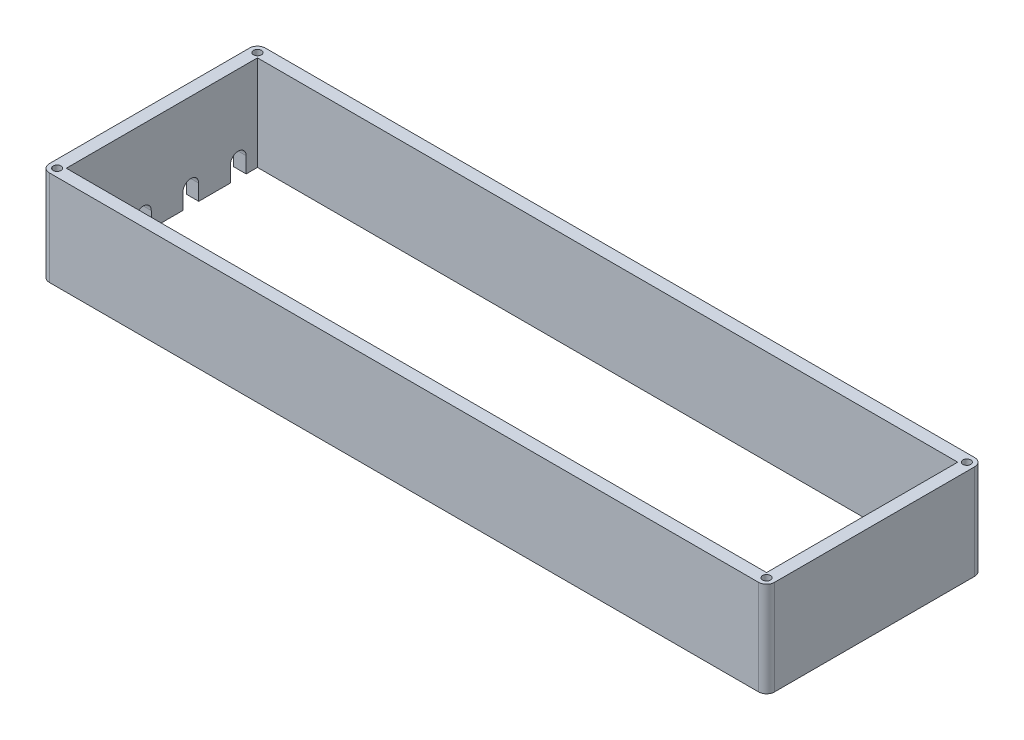
from build123d import *

# Parameters (mm, degrees)
SKETCH1_R           = 3.175
SKETCH1_W           = 562.160000372
SKETCH1_H           = 153.482
BOSS_EXTRUDE1_DEPTH = 76.2
CUT_EXTRUDE1_REACH  = 662.854


with BuildPart() as part:
    # Sketch1 → Boss-Extrude1 (new body)
    with BuildSketch(Plane(origin=(0, 0, 0), x_dir=(1, 0, 0), z_dir=(0, 1, 0))):
        with BuildLine():
            Line((-514.30312852, -129.851740003), (-1083.763128892, -129.851740003))
            ThreePointArc((-1083.763128892, -129.851740003), (-1088.253256953, -131.711611942), (-1090.113128892, -136.201740003))
            Line((-1090.113128892, -136.201740003), (-1090.113128892, -296.983740003))
            ThreePointArc((-1090.113128892, -296.983740003), (-1088.253256953, -301.473868063), (-1083.763128892, -303.333740003))
            Line((-1083.763128892, -303.333740003), (-514.30312852, -303.333740003))
            ThreePointArc((-514.30312852, -303.333740003), (-509.81300046, -301.473868063), (-507.95312852, -296.983740003))
            Line((-507.95312852, -296.983740003), (-507.95312852, -136.201740003))
            ThreePointArc((-507.95312852, -136.201740003), (-509.81300046, -131.711611942), (-514.30312852, -129.851740003))
        make_face()
        with Locations(Location((-1083.763128892, -136.201740003, 0), (0, 0, 90))):
            Circle(SKETCH1_R, mode=Mode.SUBTRACT)
        with Locations(Location((-1083.763128892, -296.983740003, 0), (0, 0, 90))):
            Circle(SKETCH1_R, mode=Mode.SUBTRACT)
        with Locations(Location((-514.30312852, -136.201740003, 0), (0, 0, 90))):
            Circle(SKETCH1_R, mode=Mode.SUBTRACT)
        with Locations(Location((-514.30312852, -296.983740003, 0), (0, 0, 90))):
            Circle(SKETCH1_R, mode=Mode.SUBTRACT)
        with Locations((-799.033128706, -216.592740003)):
            Rectangle(SKETCH1_W, SKETCH1_H, mode=Mode.SUBTRACT)
    extrude(amount=BOSS_EXTRUDE1_DEPTH)

    # Sketch3 → Cut-Extrude1 (cut, up to next)
    with BuildSketch(Plane.ZY.offset(1090.113128892), mode=Mode.PRIVATE) as cut_extrude1_sk1:
        with BuildLine():
            Line((161.601740003, 0), (148.901740003, 0))
            Line((148.901740003, 0), (148.901740003, 12.7))
            ThreePointArc((148.901740003, 12.7), (155.251740003, 19.05), (161.601740003, 12.7))
            Line((161.601740003, 12.7), (161.601740003, 0))
        make_face()
    cut_extrude1_tool1 = extrude(cut_extrude1_sk1.sketch, amount=-CUT_EXTRUDE1_REACH, mode=Mode.PRIVATE) & part.part
    # Sketch3 → Cut-Extrude1 (cut, up to next)
    with BuildSketch(Plane.ZY.offset(1090.113128892), mode=Mode.PRIVATE) as cut_extrude1_sk2:
        with BuildLine():
            Line((199.701740003, 0), (187.001740003, 0))
            Line((187.001740003, 0), (187.001740003, 12.7))
            ThreePointArc((187.001740003, 12.7), (193.351740003, 19.05), (199.701740003, 12.7))
            Line((199.701740003, 12.7), (199.701740003, 0))
        make_face()
    cut_extrude1_tool2 = extrude(cut_extrude1_sk2.sketch, amount=-CUT_EXTRUDE1_REACH, mode=Mode.PRIVATE) & part.part
    # Sketch3 → Cut-Extrude1 (cut, up to next)
    with BuildSketch(Plane.ZY.offset(1090.113128892), mode=Mode.PRIVATE) as cut_extrude1_sk3:
        with BuildLine():
            Line((237.801740003, 0), (225.101740003, 0))
            Line((225.101740003, 0), (225.101740003, 12.7))
            ThreePointArc((225.101740003, 12.7), (231.451740003, 19.05), (237.801740003, 12.7))
            Line((237.801740003, 12.7), (237.801740003, 0))
        make_face()
    cut_extrude1_tool3 = extrude(cut_extrude1_sk3.sketch, amount=-CUT_EXTRUDE1_REACH, mode=Mode.PRIVATE) & part.part
    # Sketch3 → Cut-Extrude1 (cut, up to next)
    with BuildSketch(Plane.ZY.offset(1090.113128892), mode=Mode.PRIVATE) as cut_extrude1_sk4:
        with BuildLine():
            Line((275.901740003, 0), (263.201740003, 0))
            Line((263.201740003, 0), (263.201740003, 12.7))
            ThreePointArc((263.201740003, 12.7), (269.551740003, 19.05), (275.901740003, 12.7))
            Line((275.901740003, 12.7), (275.901740003, 0))
        make_face()
    cut_extrude1_tool4 = extrude(cut_extrude1_sk4.sketch, amount=-CUT_EXTRUDE1_REACH, mode=Mode.PRIVATE) & part.part
    add(cut_extrude1_tool1.solids().sort_by_distance((-1090.113129, 8.900424, 155.25174))[0], mode=Mode.SUBTRACT)
    add(cut_extrude1_tool2.solids().sort_by_distance((-1090.113129, 8.900424, 193.35174))[0], mode=Mode.SUBTRACT)
    add(cut_extrude1_tool3.solids().sort_by_distance((-1090.113129, 8.900424, 231.45174))[0], mode=Mode.SUBTRACT)
    add(cut_extrude1_tool4.solids().sort_by_distance((-1090.113129, 8.900424, 269.55174))[0], mode=Mode.SUBTRACT)


solid = part.part
